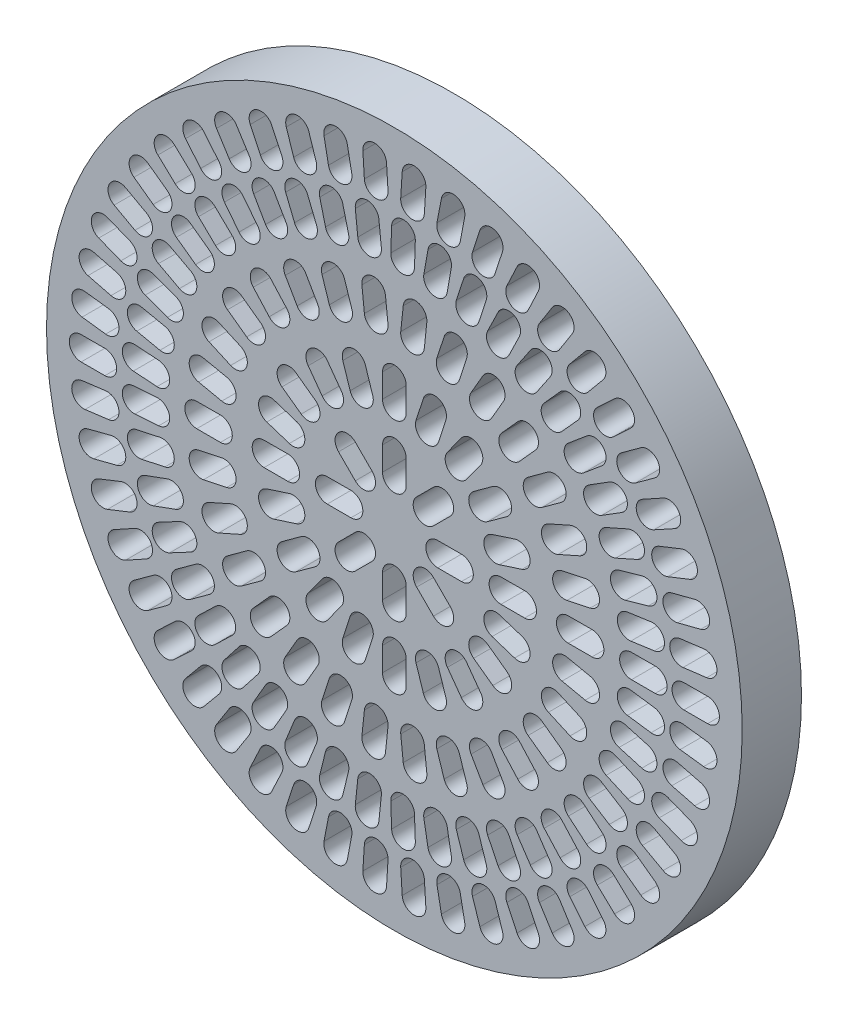
from build123d import *

# Parameters (mm, degrees)
SKETCH1_R           = 29.34
BOSS_EXTRUDE1_DEPTH = 5


with BuildPart() as part:
    # Sketch1 → Boss-Extrude1 (new body)
    with BuildSketch(Plane.XY):
        Circle(SKETCH1_R)
        with BuildLine():
            Line((3.66, 1), (5.66, 1))
            ThreePointArc((5.66, 1), (6.66, 0), (5.66, -1))
            Line((5.66, -1), (3.66, -1))
            ThreePointArc((3.66, -1), (2.66, 0), (3.66, 1))
        make_face(mode=Mode.SUBTRACT)
        with BuildLine():
            Line((10.99, -1), (8.99, -1))
            ThreePointArc((8.99, -1), (7.99, 0), (8.99, 1))
            Line((8.99, 1), (10.99, 1))
            ThreePointArc((10.99, 1), (11.99, 0), (10.99, -1))
        make_face(mode=Mode.SUBTRACT)
        with BuildLine():
            Line((14.67, 1), (16.67, 1))
            ThreePointArc((16.67, 1), (17.67, 0), (16.67, -1))
            Line((16.67, -1), (14.67, -1))
            ThreePointArc((14.67, -1), (13.67, 0), (14.67, 1))
        make_face(mode=Mode.SUBTRACT)
        with BuildLine():
            Line((20, 1), (22, 1))
            ThreePointArc((22, 1), (23, 0), (22, -1))
            Line((22, -1), (20, -1))
            ThreePointArc((20, -1), (19, 0), (20, 1))
        make_face(mode=Mode.SUBTRACT)
        with BuildLine():
            Line((24.420042908, 1), (26.420042908, 1))
            ThreePointArc((26.420042908, 1), (27.420042908, 0), (26.420042908, -1))
            Line((26.420042908, -1), (24.420042908, -1))
            ThreePointArc((24.420042908, -1), (23.420042908, 0), (24.420042908, 1))
        make_face(mode=Mode.SUBTRACT)
        with BuildLine():
            Line((3.2951176, -1.880904038), (4.709331163, -3.2951176))
            ThreePointArc((4.709331163, -3.2951176), (4.709331163, -4.709331163), (3.2951176, -4.709331163))
            Line((3.2951176, -4.709331163), (1.880904038, -3.2951176))
            ThreePointArc((1.880904038, -3.2951176), (1.880904038, -1.880904038), (3.2951176, -1.880904038))
        make_face(mode=Mode.SUBTRACT)
        with BuildLine():
            Line((1, -3.66), (1, -5.66))
            ThreePointArc((1, -5.66), (0, -6.66), (-1, -5.66))
            Line((-1, -5.66), (-1, -3.66))
            ThreePointArc((-1, -3.66), (0, -2.66), (1, -3.66))
        make_face(mode=Mode.SUBTRACT)
        with BuildLine():
            Line((-1.880904038, -3.2951176), (-3.2951176, -4.709331163))
            ThreePointArc((-3.2951176, -4.709331163), (-4.709331163, -4.709331163), (-4.709331163, -3.2951176))
            Line((-4.709331163, -3.2951176), (-3.2951176, -1.880904038))
            ThreePointArc((-3.2951176, -1.880904038), (-1.880904038, -1.880904038), (-1.880904038, -3.2951176))
        make_face(mode=Mode.SUBTRACT)
        with BuildLine():
            Line((-3.66, -1), (-5.66, -1))
            ThreePointArc((-5.66, -1), (-6.66, 0), (-5.66, 1))
            Line((-5.66, 1), (-3.66, 1))
            ThreePointArc((-3.66, 1), (-2.66, 0), (-3.66, -1))
        make_face(mode=Mode.SUBTRACT)
        with BuildLine():
            Line((-3.2951176, 1.880904038), (-4.709331163, 3.2951176))
            ThreePointArc((-4.709331163, 3.2951176), (-4.709331163, 4.709331163), (-3.2951176, 4.709331163))
            Line((-3.2951176, 4.709331163), (-1.880904038, 3.2951176))
            ThreePointArc((-1.880904038, 3.2951176), (-1.880904038, 1.880904038), (-3.2951176, 1.880904038))
        make_face(mode=Mode.SUBTRACT)
        with BuildLine():
            Line((-1, 3.66), (-1, 5.66))
            ThreePointArc((-1, 5.66), (0, 6.66), (1, 5.66))
            Line((1, 5.66), (1, 3.66))
            ThreePointArc((1, 3.66), (0, 2.66), (-1, 3.66))
        make_face(mode=Mode.SUBTRACT)
        with BuildLine():
            Line((1.880904038, 3.2951176), (3.2951176, 4.709331163))
            ThreePointArc((3.2951176, 4.709331163), (4.709331163, 4.709331163), (4.709331163, 3.2951176))
            Line((4.709331163, 3.2951176), (3.2951176, 1.880904038))
            ThreePointArc((3.2951176, 1.880904038), (1.880904038, 1.880904038), (1.880904038, 3.2951176))
        make_face(mode=Mode.SUBTRACT)
        with BuildLine():
            Line((10.14309412, -4.347153284), (8.240981087, -3.729119296))
            ThreePointArc((8.240981087, -3.729119296), (7.598941565, -2.469045785), (8.859015076, -1.827006263))
            Line((8.859015076, -1.827006263), (10.761128108, -2.445040252))
            ThreePointArc((10.761128108, -2.445040252), (11.40316763, -3.705113763), (10.14309412, -4.347153284))
        make_face(mode=Mode.SUBTRACT)
        with BuildLine():
            Line((8.303311516, -7.268776917), (6.685277527, -6.093206412))
            ThreePointArc((6.685277527, -6.093206412), (6.464045785, -4.696404166), (7.860848032, -4.475172424))
            Line((7.860848032, -4.475172424), (9.47888202, -5.650742928))
            ThreePointArc((9.47888202, -5.650742928), (9.700113763, -7.047545175), (8.303311516, -7.268776917))
        make_face(mode=Mode.SUBTRACT)
        with BuildLine():
            Line((5.650742928, -9.47888202), (4.475172424, -7.860848032))
            ThreePointArc((4.475172424, -7.860848032), (4.696404166, -6.464045785), (6.093206412, -6.685277527))
            Line((6.093206412, -6.685277527), (7.268776917, -8.303311516))
            ThreePointArc((7.268776917, -8.303311516), (7.047545175, -9.700113763), (5.650742928, -9.47888202))
        make_face(mode=Mode.SUBTRACT)
        with BuildLine():
            Line((2.445040252, -10.761128108), (1.827006263, -8.859015076))
            ThreePointArc((1.827006263, -8.859015076), (2.469045785, -7.598941565), (3.729119296, -8.240981087))
            Line((3.729119296, -8.240981087), (4.347153284, -10.14309412))
            ThreePointArc((4.347153284, -10.14309412), (3.705113763, -11.40316763), (2.445040252, -10.761128108))
        make_face(mode=Mode.SUBTRACT)
        with BuildLine():
            Line((-1, -10.99), (-1, -8.99))
            ThreePointArc((-1, -8.99), (0, -7.99), (1, -8.99))
            Line((1, -8.99), (1, -10.99))
            ThreePointArc((1, -10.99), (0, -11.99), (-1, -10.99))
        make_face(mode=Mode.SUBTRACT)
        with BuildLine():
            Line((-4.347153284, -10.14309412), (-3.729119296, -8.240981087))
            ThreePointArc((-3.729119296, -8.240981087), (-2.469045785, -7.598941565), (-1.827006263, -8.859015076))
            Line((-1.827006263, -8.859015076), (-2.445040252, -10.761128108))
            ThreePointArc((-2.445040252, -10.761128108), (-3.705113763, -11.40316763), (-4.347153284, -10.14309412))
        make_face(mode=Mode.SUBTRACT)
        with BuildLine():
            Line((-7.268776917, -8.303311516), (-6.093206412, -6.685277527))
            ThreePointArc((-6.093206412, -6.685277527), (-4.696404166, -6.464045785), (-4.475172424, -7.860848032))
            Line((-4.475172424, -7.860848032), (-5.650742928, -9.47888202))
            ThreePointArc((-5.650742928, -9.47888202), (-7.047545175, -9.700113763), (-7.268776917, -8.303311516))
        make_face(mode=Mode.SUBTRACT)
        with BuildLine():
            Line((-9.47888202, -5.650742928), (-7.860848032, -4.475172424))
            ThreePointArc((-7.860848032, -4.475172424), (-6.464045785, -4.696404166), (-6.685277527, -6.093206412))
            Line((-6.685277527, -6.093206412), (-8.303311516, -7.268776917))
            ThreePointArc((-8.303311516, -7.268776917), (-9.700113763, -7.047545175), (-9.47888202, -5.650742928))
        make_face(mode=Mode.SUBTRACT)
        with BuildLine():
            Line((-10.761128108, -2.445040252), (-8.859015076, -1.827006263))
            ThreePointArc((-8.859015076, -1.827006263), (-7.598941565, -2.469045785), (-8.240981087, -3.729119296))
            Line((-8.240981087, -3.729119296), (-10.14309412, -4.347153284))
            ThreePointArc((-10.14309412, -4.347153284), (-11.40316763, -3.705113763), (-10.761128108, -2.445040252))
        make_face(mode=Mode.SUBTRACT)
        with BuildLine():
            Line((-10.99, 1), (-8.99, 1))
            ThreePointArc((-8.99, 1), (-7.99, 0), (-8.99, -1))
            Line((-8.99, -1), (-10.99, -1))
            ThreePointArc((-10.99, -1), (-11.99, 0), (-10.99, 1))
        make_face(mode=Mode.SUBTRACT)
        with BuildLine():
            Line((-10.14309412, 4.347153284), (-8.240981087, 3.729119296))
            ThreePointArc((-8.240981087, 3.729119296), (-7.598941565, 2.469045785), (-8.859015076, 1.827006263))
            Line((-8.859015076, 1.827006263), (-10.761128108, 2.445040252))
            ThreePointArc((-10.761128108, 2.445040252), (-11.40316763, 3.705113763), (-10.14309412, 4.347153284))
        make_face(mode=Mode.SUBTRACT)
        with BuildLine():
            Line((-8.303311516, 7.268776917), (-6.685277527, 6.093206412))
            ThreePointArc((-6.685277527, 6.093206412), (-6.464045785, 4.696404166), (-7.860848032, 4.475172424))
            Line((-7.860848032, 4.475172424), (-9.47888202, 5.650742928))
            ThreePointArc((-9.47888202, 5.650742928), (-9.700113763, 7.047545175), (-8.303311516, 7.268776917))
        make_face(mode=Mode.SUBTRACT)
        with BuildLine():
            Line((-5.650742928, 9.47888202), (-4.475172424, 7.860848032))
            ThreePointArc((-4.475172424, 7.860848032), (-4.696404166, 6.464045785), (-6.093206412, 6.685277527))
            Line((-6.093206412, 6.685277527), (-7.268776917, 8.303311516))
            ThreePointArc((-7.268776917, 8.303311516), (-7.047545175, 9.700113763), (-5.650742928, 9.47888202))
        make_face(mode=Mode.SUBTRACT)
        with BuildLine():
            Line((-2.445040252, 10.761128108), (-1.827006263, 8.859015076))
            ThreePointArc((-1.827006263, 8.859015076), (-2.469045785, 7.598941565), (-3.729119296, 8.240981087))
            Line((-3.729119296, 8.240981087), (-4.347153284, 10.14309412))
            ThreePointArc((-4.347153284, 10.14309412), (-3.705113763, 11.40316763), (-2.445040252, 10.761128108))
        make_face(mode=Mode.SUBTRACT)
        with BuildLine():
            Line((1, 10.99), (1, 8.99))
            ThreePointArc((1, 8.99), (0, 7.99), (-1, 8.99))
            Line((-1, 8.99), (-1, 10.99))
            ThreePointArc((-1, 10.99), (0, 11.99), (1, 10.99))
        make_face(mode=Mode.SUBTRACT)
        with BuildLine():
            Line((4.347153284, 10.14309412), (3.729119296, 8.240981087))
            ThreePointArc((3.729119296, 8.240981087), (2.469045785, 7.598941565), (1.827006263, 8.859015076))
            Line((1.827006263, 8.859015076), (2.445040252, 10.761128108))
            ThreePointArc((2.445040252, 10.761128108), (3.705113763, 11.40316763), (4.347153284, 10.14309412))
        make_face(mode=Mode.SUBTRACT)
        with BuildLine():
            Line((7.268776917, 8.303311516), (6.093206412, 6.685277527))
            ThreePointArc((6.093206412, 6.685277527), (4.696404166, 6.464045785), (4.475172424, 7.860848032))
            Line((4.475172424, 7.860848032), (5.650742928, 9.47888202))
            ThreePointArc((5.650742928, 9.47888202), (7.047545175, 9.700113763), (7.268776917, 8.303311516))
        make_face(mode=Mode.SUBTRACT)
        with BuildLine():
            Line((9.47888202, 5.650742928), (7.860848032, 4.475172424))
            ThreePointArc((7.860848032, 4.475172424), (6.464045785, 4.696404166), (6.685277527, 6.093206412))
            Line((6.685277527, 6.093206412), (8.303311516, 7.268776917))
            ThreePointArc((8.303311516, 7.268776917), (9.700113763, 7.047545175), (9.47888202, 5.650742928))
        make_face(mode=Mode.SUBTRACT)
        with BuildLine():
            Line((10.761128108, 2.445040252), (8.859015076, 1.827006263))
            ThreePointArc((8.859015076, 1.827006263), (7.598941565, 2.469045785), (8.240981087, 3.729119296))
            Line((8.240981087, 3.729119296), (10.14309412, 4.347153284))
            ThreePointArc((10.14309412, 4.347153284), (11.40316763, 3.705113763), (10.761128108, 2.445040252))
        make_face(mode=Mode.SUBTRACT)
        with BuildLine():
            Line((14.557336994, -2.071916904), (16.513632195, -2.487740285))
            ThreePointArc((16.513632195, -2.487740285), (17.283868105, -3.673799577), (16.097808813, -4.444035487))
            Line((16.097808813, -4.444035487), (14.141513612, -4.028212105))
            ThreePointArc((14.141513612, -4.028212105), (13.371277702, -2.842152813), (14.557336994, -2.071916904))
        make_face(mode=Mode.SUBTRACT)
        with BuildLine():
            Line((13.808448507, -5.053281096), (15.635539422, -5.866754382))
            ThreePointArc((15.635539422, -5.866754382), (16.142348237, -7.187036483), (14.822066136, -7.693845298))
            Line((14.822066136, -7.693845298), (12.994975221, -6.880372012))
            ThreePointArc((12.994975221, -6.880372012), (12.488166406, -5.560089911), (13.808448507, -5.053281096))
        make_face(mode=Mode.SUBTRACT)
        with BuildLine():
            Line((12.45606456, -7.813792657), (14.074098549, -8.989363161))
            ThreePointArc((14.074098549, -8.989363161), (14.295330291, -10.386165408), (12.898528044, -10.60739715))
            Line((12.898528044, -10.60739715), (11.280494055, -9.431826646))
            ThreePointArc((11.280494055, -9.431826646), (11.059262313, -8.035024399), (12.45606456, -7.813792657))
        make_face(mode=Mode.SUBTRACT)
        with BuildLine():
            Line((10.559290821, -10.232803983), (11.897552033, -11.719093634))
            ThreePointArc((11.897552033, -11.719093634), (11.823537814, -13.131369066), (10.411262383, -13.057354847))
            Line((10.411262383, -13.057354847), (9.07300117, -11.571065196))
            ThreePointArc((9.07300117, -11.571065196), (9.147015389, -10.158789764), (10.559290821, -10.232803983))
        make_face(mode=Mode.SUBTRACT)
        with BuildLine():
            Line((8.201025404, -12.204592674), (9.201025404, -13.936643481))
            ThreePointArc((9.201025404, -13.936643481), (8.835, -15.302668885), (7.468974596, -14.936643481))
            Line((7.468974596, -14.936643481), (6.468974596, -13.204592674))
            ThreePointArc((6.468974596, -13.204592674), (6.835, -11.83856727), (8.201025404, -12.204592674))
        make_face(mode=Mode.SUBTRACT)
        with BuildLine():
            Line((5.484335824, -13.6429821), (6.102369813, -15.545095132))
            ThreePointArc((6.102369813, -15.545095132), (5.460330291, -16.805168643), (4.20025678, -16.163129121))
            Line((4.20025678, -16.163129121), (3.582222791, -14.261016088))
            ThreePointArc((3.582222791, -14.261016088), (4.224262313, -13.000942578), (5.484335824, -13.6429821))
        make_face(mode=Mode.SUBTRACT)
        with BuildLine():
            Line((2.527954452, -14.485107742), (2.737011378, -16.474151533))
            ThreePointArc((2.737011378, -16.474151533), (1.847017946, -17.573201891), (0.747967587, -16.683208459))
            Line((0.747967587, -16.683208459), (0.538910661, -14.694164668))
            ThreePointArc((0.538910661, -14.694164668), (1.428904093, -13.59511431), (2.527954452, -14.485107742))
        make_face(mode=Mode.SUBTRACT)
        with BuildLine():
            Line((-0.538910661, -14.694164668), (-0.747967587, -16.683208459))
            ThreePointArc((-0.747967587, -16.683208459), (-1.847017946, -17.573201891), (-2.737011378, -16.474151533))
            Line((-2.737011378, -16.474151533), (-2.527954452, -14.485107742))
            ThreePointArc((-2.527954452, -14.485107742), (-1.428904093, -13.59511431), (-0.538910661, -14.694164668))
        make_face(mode=Mode.SUBTRACT)
        with BuildLine():
            Line((-3.582222791, -14.261016088), (-4.20025678, -16.163129121))
            ThreePointArc((-4.20025678, -16.163129121), (-5.460330291, -16.805168643), (-6.102369813, -15.545095132))
            Line((-6.102369813, -15.545095132), (-5.484335824, -13.6429821))
            ThreePointArc((-5.484335824, -13.6429821), (-4.224262313, -13.000942578), (-3.582222791, -14.261016088))
        make_face(mode=Mode.SUBTRACT)
        with BuildLine():
            Line((-6.468974596, -13.204592674), (-7.468974596, -14.936643481))
            ThreePointArc((-7.468974596, -14.936643481), (-8.835, -15.302668885), (-9.201025404, -13.936643481))
            Line((-9.201025404, -13.936643481), (-8.201025404, -12.204592674))
            ThreePointArc((-8.201025404, -12.204592674), (-6.835, -11.83856727), (-6.468974596, -13.204592674))
        make_face(mode=Mode.SUBTRACT)
        with BuildLine():
            Line((-9.07300117, -11.571065196), (-10.411262383, -13.057354847))
            ThreePointArc((-10.411262383, -13.057354847), (-11.823537814, -13.131369066), (-11.897552033, -11.719093634))
            Line((-11.897552033, -11.719093634), (-10.559290821, -10.232803983))
            ThreePointArc((-10.559290821, -10.232803983), (-9.147015389, -10.158789764), (-9.07300117, -11.571065196))
        make_face(mode=Mode.SUBTRACT)
        with BuildLine():
            Line((-11.280494055, -9.431826646), (-12.898528044, -10.60739715))
            ThreePointArc((-12.898528044, -10.60739715), (-14.295330291, -10.386165408), (-14.074098549, -8.989363161))
            Line((-14.074098549, -8.989363161), (-12.45606456, -7.813792657))
            ThreePointArc((-12.45606456, -7.813792657), (-11.059262313, -8.035024399), (-11.280494055, -9.431826646))
        make_face(mode=Mode.SUBTRACT)
        with BuildLine():
            Line((-12.994975221, -6.880372012), (-14.822066136, -7.693845298))
            ThreePointArc((-14.822066136, -7.693845298), (-16.142348237, -7.187036483), (-15.635539422, -5.866754382))
            Line((-15.635539422, -5.866754382), (-13.808448507, -5.053281096))
            ThreePointArc((-13.808448507, -5.053281096), (-12.488166406, -5.560089911), (-12.994975221, -6.880372012))
        make_face(mode=Mode.SUBTRACT)
        with BuildLine():
            Line((-14.141513612, -4.028212105), (-16.097808813, -4.444035487))
            ThreePointArc((-16.097808813, -4.444035487), (-17.283868105, -3.673799577), (-16.513632195, -2.487740285))
            Line((-16.513632195, -2.487740285), (-14.557336994, -2.071916904))
            ThreePointArc((-14.557336994, -2.071916904), (-13.371277702, -2.842152813), (-14.141513612, -4.028212105))
        make_face(mode=Mode.SUBTRACT)
        with BuildLine():
            Line((-14.67, -1), (-16.67, -1))
            ThreePointArc((-16.67, -1), (-17.67, 0), (-16.67, 1))
            Line((-16.67, 1), (-14.67, 1))
            ThreePointArc((-14.67, 1), (-13.67, 0), (-14.67, -1))
        make_face(mode=Mode.SUBTRACT)
        with BuildLine():
            Line((-14.557336994, 2.071916904), (-16.513632195, 2.487740285))
            ThreePointArc((-16.513632195, 2.487740285), (-17.283868105, 3.673799577), (-16.097808813, 4.444035487))
            Line((-16.097808813, 4.444035487), (-14.141513612, 4.028212105))
            ThreePointArc((-14.141513612, 4.028212105), (-13.371277702, 2.842152813), (-14.557336994, 2.071916904))
        make_face(mode=Mode.SUBTRACT)
        with BuildLine():
            Line((-13.808448507, 5.053281096), (-15.635539422, 5.866754382))
            ThreePointArc((-15.635539422, 5.866754382), (-16.142348237, 7.187036483), (-14.822066136, 7.693845298))
            Line((-14.822066136, 7.693845298), (-12.994975221, 6.880372012))
            ThreePointArc((-12.994975221, 6.880372012), (-12.488166406, 5.560089911), (-13.808448507, 5.053281096))
        make_face(mode=Mode.SUBTRACT)
        with BuildLine():
            Line((-12.45606456, 7.813792657), (-14.074098549, 8.989363161))
            ThreePointArc((-14.074098549, 8.989363161), (-14.295330291, 10.386165408), (-12.898528044, 10.60739715))
            Line((-12.898528044, 10.60739715), (-11.280494055, 9.431826646))
            ThreePointArc((-11.280494055, 9.431826646), (-11.059262313, 8.035024399), (-12.45606456, 7.813792657))
        make_face(mode=Mode.SUBTRACT)
        with BuildLine():
            Line((-10.559290821, 10.232803983), (-11.897552033, 11.719093634))
            ThreePointArc((-11.897552033, 11.719093634), (-11.823537814, 13.131369066), (-10.411262383, 13.057354847))
            Line((-10.411262383, 13.057354847), (-9.07300117, 11.571065196))
            ThreePointArc((-9.07300117, 11.571065196), (-9.147015389, 10.158789764), (-10.559290821, 10.232803983))
        make_face(mode=Mode.SUBTRACT)
        with BuildLine():
            Line((-8.201025404, 12.204592674), (-9.201025404, 13.936643481))
            ThreePointArc((-9.201025404, 13.936643481), (-8.835, 15.302668885), (-7.468974596, 14.936643481))
            Line((-7.468974596, 14.936643481), (-6.468974596, 13.204592674))
            ThreePointArc((-6.468974596, 13.204592674), (-6.835, 11.83856727), (-8.201025404, 12.204592674))
        make_face(mode=Mode.SUBTRACT)
        with BuildLine():
            Line((-5.484335824, 13.6429821), (-6.102369813, 15.545095132))
            ThreePointArc((-6.102369813, 15.545095132), (-5.460330291, 16.805168643), (-4.20025678, 16.163129121))
            Line((-4.20025678, 16.163129121), (-3.582222791, 14.261016088))
            ThreePointArc((-3.582222791, 14.261016088), (-4.224262313, 13.000942578), (-5.484335824, 13.6429821))
        make_face(mode=Mode.SUBTRACT)
        with BuildLine():
            Line((-2.527954452, 14.485107742), (-2.737011378, 16.474151533))
            ThreePointArc((-2.737011378, 16.474151533), (-1.847017946, 17.573201891), (-0.747967587, 16.683208459))
            Line((-0.747967587, 16.683208459), (-0.538910661, 14.694164668))
            ThreePointArc((-0.538910661, 14.694164668), (-1.428904093, 13.59511431), (-2.527954452, 14.485107742))
        make_face(mode=Mode.SUBTRACT)
        with BuildLine():
            Line((0.538910661, 14.694164668), (0.747967587, 16.683208459))
            ThreePointArc((0.747967587, 16.683208459), (1.847017946, 17.573201891), (2.737011378, 16.474151533))
            Line((2.737011378, 16.474151533), (2.527954452, 14.485107742))
            ThreePointArc((2.527954452, 14.485107742), (1.428904093, 13.59511431), (0.538910661, 14.694164668))
        make_face(mode=Mode.SUBTRACT)
        with BuildLine():
            Line((3.582222791, 14.261016088), (4.20025678, 16.163129121))
            ThreePointArc((4.20025678, 16.163129121), (5.460330291, 16.805168643), (6.102369813, 15.545095132))
            Line((6.102369813, 15.545095132), (5.484335824, 13.6429821))
            ThreePointArc((5.484335824, 13.6429821), (4.224262313, 13.000942578), (3.582222791, 14.261016088))
        make_face(mode=Mode.SUBTRACT)
        with BuildLine():
            Line((6.468974596, 13.204592674), (7.468974596, 14.936643481))
            ThreePointArc((7.468974596, 14.936643481), (8.835, 15.302668885), (9.201025404, 13.936643481))
            Line((9.201025404, 13.936643481), (8.201025404, 12.204592674))
            ThreePointArc((8.201025404, 12.204592674), (6.835, 11.83856727), (6.468974596, 13.204592674))
        make_face(mode=Mode.SUBTRACT)
        with BuildLine():
            Line((9.07300117, 11.571065196), (10.411262383, 13.057354847))
            ThreePointArc((10.411262383, 13.057354847), (11.823537814, 13.131369066), (11.897552033, 11.719093634))
            Line((11.897552033, 11.719093634), (10.559290821, 10.232803983))
            ThreePointArc((10.559290821, 10.232803983), (9.147015389, 10.158789764), (9.07300117, 11.571065196))
        make_face(mode=Mode.SUBTRACT)
        with BuildLine():
            Line((11.280494055, 9.431826646), (12.898528044, 10.60739715))
            ThreePointArc((12.898528044, 10.60739715), (14.295330291, 10.386165408), (14.074098549, 8.989363161))
            Line((14.074098549, 8.989363161), (12.45606456, 7.813792657))
            ThreePointArc((12.45606456, 7.813792657), (11.059262313, 8.035024399), (11.280494055, 9.431826646))
        make_face(mode=Mode.SUBTRACT)
        with BuildLine():
            Line((12.994975221, 6.880372012), (14.822066136, 7.693845298))
            ThreePointArc((14.822066136, 7.693845298), (16.142348237, 7.187036483), (15.635539422, 5.866754382))
            Line((15.635539422, 5.866754382), (13.808448507, 5.053281096))
            ThreePointArc((13.808448507, 5.053281096), (12.488166406, 5.560089911), (12.994975221, 6.880372012))
        make_face(mode=Mode.SUBTRACT)
        with BuildLine():
            Line((14.141513612, 4.028212105), (16.097808813, 4.444035487))
            ThreePointArc((16.097808813, 4.444035487), (17.283868105, 3.673799577), (16.513632195, 2.487740285))
            Line((16.513632195, 2.487740285), (14.557336994, 2.071916904))
            ThreePointArc((14.557336994, 2.071916904), (13.371277702, 2.842152813), (14.141513612, 4.028212105))
        make_face(mode=Mode.SUBTRACT)
        with BuildLine():
            Line((19.944534476, -1.79319395), (21.925070613, -2.071540152))
            ThreePointArc((21.925070613, -2.071540152), (22.776165581, -3.200981322), (21.646724411, -4.05207629))
            Line((21.646724411, -4.05207629), (19.666188274, -3.773730088))
            ThreePointArc((19.666188274, -3.773730088), (18.815093306, -2.644288918), (19.944534476, -1.79319395))
        make_face(mode=Mode.SUBTRACT)
        with BuildLine():
            Line((19.500871275, -4.55148542), (21.423394666, -5.102760132))
            ThreePointArc((21.423394666, -5.102760132), (22.109019007, -6.339659184), (20.872119955, -7.025283524))
            Line((20.872119955, -7.025283524), (18.949596563, -6.474008812))
            ThreePointArc((18.949596563, -6.474008812), (18.263972223, -5.237109761), (19.500871275, -4.55148542))
        make_face(mode=Mode.SUBTRACT)
        with BuildLine():
            Line((18.677645796, -7.221187404), (20.504736711, -8.03466069))
            ThreePointArc((20.504736711, -8.03466069), (21.011545526, -9.354942791), (19.691263425, -9.861751605))
            Line((19.691263425, -9.861751605), (17.86417251, -9.048278319))
            ThreePointArc((17.86417251, -9.048278319), (17.357363695, -7.727996218), (18.677645796, -7.221187404))
        make_face(mode=Mode.SUBTRACT)
        with BuildLine():
            Line((17.490881187, -9.750337189), (19.18697738, -10.810175717))
            ThreePointArc((19.18697738, -10.810175717), (19.505106212, -12.188143077), (18.127138851, -12.506271909))
            Line((18.127138851, -12.506271909), (16.431042659, -11.446433381))
            ThreePointArc((16.431042659, -11.446433381), (16.112913827, -10.06846602), (17.490881187, -9.750337189))
        make_face(mode=Mode.SUBTRACT)
        with BuildLine():
            Line((15.963676472, -12.089707751), (17.495765358, -13.37528297))
            ThreePointArc((17.495765358, -13.37528297), (17.619022192, -14.784115023), (16.210190139, -14.907371856))
            Line((16.210190139, -14.907371856), (14.678101253, -13.621796637))
            ThreePointArc((14.678101253, -13.621796637), (14.554844419, -12.212964584), (15.963676472, -12.089707751))
        make_face(mode=Mode.SUBTRACT)
        with BuildLine():
            Line((14.125756953, -14.193765903), (15.464018165, -15.680055554))
            ThreePointArc((15.464018165, -15.680055554), (15.390003946, -17.092330986), (13.977728514, -17.018316767))
            Line((13.977728514, -17.018316767), (12.639467302, -15.532027116))
            ThreePointArc((12.639467302, -15.532027116), (12.713481521, -14.119751684), (14.125756953, -14.193765903))
        make_face(mode=Mode.SUBTRACT)
        with BuildLine():
            Line((12.012895642, -16.021558548), (13.131281449, -17.679633693))
            ThreePointArc((13.131281449, -17.679633693), (12.86143678, -19.067864169), (11.473206304, -18.7980195))
            Line((11.473206304, -18.7980195), (10.354820497, -17.139944355))
            ThreePointArc((10.354820497, -17.139944355), (10.624665166, -15.751713879), (12.012895642, -16.021558548))
        make_face(mode=Mode.SUBTRACT)
        with BuildLine():
            Line((9.666216982, -17.537509779), (10.542959276, -19.335097872))
            ThreePointArc((10.542959276, -19.335097872), (10.082536376, -20.672263065), (8.745371183, -20.211840165))
            Line((8.745371183, -20.211840165), (7.868628889, -18.414252073))
            ThreePointArc((7.868628889, -18.414252073), (8.329051789, -17.07708688), (9.666216982, -17.537509779))
        make_face(mode=Mode.SUBTRACT)
        with BuildLine():
            Line((7.131396404, -18.712113332), (7.749430393, -20.614226364))
            ThreePointArc((7.749430393, -20.614226364), (7.107390871, -21.874299875), (5.84731736, -21.232260353))
            Line((5.84731736, -21.232260353), (5.229283371, -19.33014732))
            ThreePointArc((5.229283371, -19.33014732), (5.871322893, -18.07007381), (7.131396404, -18.712113332))
        make_face(mode=Mode.SUBTRACT)
        with BuildLine():
            Line((4.457771306, -19.522506883), (4.805067662, -21.492122389))
            ThreePointArc((4.805067662, -21.492122389), (3.993908086, -22.650578319), (2.835452156, -21.839418744))
            Line((2.835452156, -21.839418744), (2.4881558, -19.869803238))
            ThreePointArc((2.4881558, -19.869803238), (3.299315376, -18.711347307), (4.457771306, -19.522506883))
        make_face(mode=Mode.SUBTRACT)
        with BuildLine():
            Line((1.697380761, -19.952917044), (1.767179754, -21.951698698))
            ThreePointArc((1.767179754, -21.951698698), (0.802688424, -22.985989021), (-0.2316019, -22.021497691))
            Line((-0.2316019, -22.021497691), (-0.301400893, -20.022716037))
            ThreePointArc((-0.301400893, -20.022716037), (0.663090437, -18.988425713), (1.697380761, -19.952917044))
        make_face(mode=Mode.SUBTRACT)
        with BuildLine():
            Line((-1.09604737, -19.994966371), (-1.305104297, -21.984010161))
            ThreePointArc((-1.305104297, -21.984010161), (-2.404154655, -22.874003593), (-3.294148087, -21.774953235))
            Line((-3.294148087, -21.774953235), (-3.085091161, -19.785909444))
            ThreePointArc((-3.085091161, -19.785909444), (-1.986040802, -18.895916012), (-1.09604737, -19.994966371))
        make_face(mode=Mode.SUBTRACT)
        with BuildLine():
            Line((-3.868142186, -19.647836421), (-4.351985977, -21.588427874))
            ThreePointArc((-4.351985977, -21.588427874), (-5.564203599, -22.316801704), (-6.292577429, -21.104584082))
            Line((-6.292577429, -21.104584082), (-5.808733638, -19.16399263))
            ThreePointArc((-5.808733638, -19.16399263), (-4.596516016, -18.435618799), (-3.868142186, -19.647836421))
        make_face(mode=Mode.SUBTRACT)
        with BuildLine():
            Line((-6.564948014, -18.918283685), (-7.314161201, -20.772651394))
            ThreePointArc((-7.314161201, -20.772651394), (-8.615951649, -21.325228655), (-9.16852891, -20.023438207))
            Line((-9.16852891, -20.023438207), (-8.419315723, -18.169070498))
            ThreePointArc((-8.419315723, -18.169070498), (-7.117525275, -17.616493237), (-6.564948014, -18.918283685))
        make_face(mode=Mode.SUBTRACT)
        with BuildLine():
            Line((-9.133974596, -17.820508076), (-10.133974596, -19.552558883))
            ThreePointArc((-10.133974596, -19.552558883), (-11.5, -19.918584287), (-11.866025404, -18.552558883))
            Line((-11.866025404, -18.552558883), (-10.866025404, -16.820508076))
            ThreePointArc((-10.866025404, -16.820508076), (-9.5, -16.454482672), (-9.133974596, -17.820508076))
        make_face(mode=Mode.SUBTRACT)
        with BuildLine():
            Line((-11.525218753, -16.375876547), (-12.756541704, -17.951898055))
            ThreePointArc((-12.756541704, -17.951898055), (-14.160213932, -18.124247333), (-14.332563211, -16.720575104))
            Line((-14.332563211, -16.720575104), (-13.10124026, -15.144553597))
            ThreePointArc((-13.10124026, -15.144553597), (-11.697568031, -14.972204319), (-11.525218753, -16.375876547))
        make_face(mode=Mode.SUBTRACT)
        with BuildLine():
            Line((-13.692137636, -14.61250721), (-15.130817237, -16.00182395))
            ThreePointArc((-15.130817237, -16.00182395), (-16.544815408, -15.977142521), (-16.520133978, -14.56314435))
            Line((-16.520133978, -14.56314435), (-15.081454377, -13.173827609))
            ThreePointArc((-15.081454377, -13.173827609), (-13.667456206, -13.198509039), (-13.692137636, -14.61250721))
        make_face(mode=Mode.SUBTRACT)
        with BuildLine():
            Line((-15.592554635, -12.56472204), (-17.210588624, -13.740292545))
            ThreePointArc((-17.210588624, -13.740292545), (-18.607390871, -13.519060803), (-18.386159129, -12.122258556))
            Line((-18.386159129, -12.122258556), (-16.76812514, -10.946688051))
            ThreePointArc((-16.76812514, -10.946688051), (-15.371322893, -11.167919794), (-15.592554635, -12.56472204))
        make_face(mode=Mode.SUBTRACT)
        with BuildLine():
            Line((-17.189480294, -10.272378849), (-18.95537548, -11.211321974))
            ThreePointArc((-18.95537548, -11.211321974), (-20.307794636, -10.797845944), (-19.894318606, -9.445426788))
            Line((-19.894318606, -9.445426788), (-18.12842342, -8.506483663))
            ThreePointArc((-18.12842342, -8.506483663), (-16.776004264, -8.919959693), (-17.189480294, -10.272378849))
        make_face(mode=Mode.SUBTRACT)
        with BuildLine():
            Line((-18.451832272, -7.780095487), (-20.331217514, -8.464135774))
            ThreePointArc((-20.331217514, -8.464135774), (-21.612930278, -7.866463296), (-21.015257801, -6.584750532))
            Line((-21.015257801, -6.584750532), (-19.135872559, -5.900710246))
            ThreePointArc((-19.135872559, -5.900710246), (-17.854159795, -6.498382723), (-18.451832272, -7.780095487))
        make_face(mode=Mode.SUBTRACT)
        with BuildLine():
            Line((-19.355040324, -5.136381417), (-21.311335525, -5.552204799))
            ThreePointArc((-21.311335525, -5.552204799), (-22.497394817, -4.781968889), (-21.727158907, -3.595909597))
            Line((-21.727158907, -3.595909597), (-19.770863705, -3.180086216))
            ThreePointArc((-19.770863705, -3.180086216), (-18.584804414, -3.950322126), (-19.355040324, -5.136381417))
        make_face(mode=Mode.SUBTRACT)
        with BuildLine():
            Line((-19.881524531, -2.392693525), (-21.876652632, -2.532206473))
            ThreePointArc((-21.876652632, -2.532206473), (-22.943973156, -1.604398896), (-22.016165579, -0.537078372))
            Line((-22.016165579, -0.537078372), (-20.021037479, -0.397565425))
            ThreePointArc((-20.021037479, -0.397565425), (-18.953716955, -1.325373001), (-19.881524531, -2.392693525))
        make_face(mode=Mode.SUBTRACT)
        with BuildLine():
            Line((-20.021037479, 0.397565425), (-22.016165579, 0.537078372))
            ThreePointArc((-22.016165579, 0.537078372), (-22.943973156, 1.604398896), (-21.876652632, 2.532206473))
            Line((-21.876652632, 2.532206473), (-19.881524531, 2.392693525))
            ThreePointArc((-19.881524531, 2.392693525), (-18.953716955, 1.325373001), (-20.021037479, 0.397565425))
        make_face(mode=Mode.SUBTRACT)
        with BuildLine():
            Line((-19.770863705, 3.180086216), (-21.727158907, 3.595909597))
            ThreePointArc((-21.727158907, 3.595909597), (-22.497394817, 4.781968889), (-21.311335525, 5.552204799))
            Line((-21.311335525, 5.552204799), (-19.355040324, 5.136381417))
            ThreePointArc((-19.355040324, 5.136381417), (-18.584804414, 3.950322126), (-19.770863705, 3.180086216))
        make_face(mode=Mode.SUBTRACT)
        with BuildLine():
            Line((-19.135872559, 5.900710246), (-21.015257801, 6.584750532))
            ThreePointArc((-21.015257801, 6.584750532), (-21.612930278, 7.866463296), (-20.331217514, 8.464135774))
            Line((-20.331217514, 8.464135774), (-18.451832272, 7.780095487))
            ThreePointArc((-18.451832272, 7.780095487), (-17.854159795, 6.498382723), (-19.135872559, 5.900710246))
        make_face(mode=Mode.SUBTRACT)
        with BuildLine():
            Line((-18.12842342, 8.506483663), (-19.894318606, 9.445426788))
            ThreePointArc((-19.894318606, 9.445426788), (-20.307794636, 10.797845944), (-18.95537548, 11.211321974))
            Line((-18.95537548, 11.211321974), (-17.189480294, 10.272378849))
            ThreePointArc((-17.189480294, 10.272378849), (-16.776004264, 8.919959693), (-18.12842342, 8.506483663))
        make_face(mode=Mode.SUBTRACT)
        with BuildLine():
            Line((-16.76812514, 10.946688051), (-18.386159129, 12.122258556))
            ThreePointArc((-18.386159129, 12.122258556), (-18.607390871, 13.519060803), (-17.210588624, 13.740292545))
            Line((-17.210588624, 13.740292545), (-15.592554635, 12.56472204))
            ThreePointArc((-15.592554635, 12.56472204), (-15.371322893, 11.167919794), (-16.76812514, 10.946688051))
        make_face(mode=Mode.SUBTRACT)
        with BuildLine():
            Line((-15.081454377, 13.173827609), (-16.520133978, 14.56314435))
            ThreePointArc((-16.520133978, 14.56314435), (-16.544815408, 15.977142521), (-15.130817237, 16.00182395))
            Line((-15.130817237, 16.00182395), (-13.692137636, 14.61250721))
            ThreePointArc((-13.692137636, 14.61250721), (-13.667456206, 13.198509039), (-15.081454377, 13.173827609))
        make_face(mode=Mode.SUBTRACT)
        with BuildLine():
            Line((-13.10124026, 15.144553597), (-14.332563211, 16.720575104))
            ThreePointArc((-14.332563211, 16.720575104), (-14.160213932, 18.124247333), (-12.756541704, 17.951898055))
            Line((-12.756541704, 17.951898055), (-11.525218753, 16.375876547))
            ThreePointArc((-11.525218753, 16.375876547), (-11.697568031, 14.972204319), (-13.10124026, 15.144553597))
        make_face(mode=Mode.SUBTRACT)
        with BuildLine():
            Line((-10.866025404, 16.820508076), (-11.866025404, 18.552558883))
            ThreePointArc((-11.866025404, 18.552558883), (-11.5, 19.918584287), (-10.133974596, 19.552558883))
            Line((-10.133974596, 19.552558883), (-9.133974596, 17.820508076))
            ThreePointArc((-9.133974596, 17.820508076), (-9.5, 16.454482672), (-10.866025404, 16.820508076))
        make_face(mode=Mode.SUBTRACT)
        with BuildLine():
            Line((-8.419315723, 18.169070498), (-9.16852891, 20.023438207))
            ThreePointArc((-9.16852891, 20.023438207), (-8.615951649, 21.325228655), (-7.314161201, 20.772651394))
            Line((-7.314161201, 20.772651394), (-6.564948014, 18.918283685))
            ThreePointArc((-6.564948014, 18.918283685), (-7.117525275, 17.616493237), (-8.419315723, 18.169070498))
        make_face(mode=Mode.SUBTRACT)
        with BuildLine():
            Line((-5.808733638, 19.16399263), (-6.292577429, 21.104584082))
            ThreePointArc((-6.292577429, 21.104584082), (-5.564203599, 22.316801704), (-4.351985977, 21.588427874))
            Line((-4.351985977, 21.588427874), (-3.868142186, 19.647836421))
            ThreePointArc((-3.868142186, 19.647836421), (-4.596516016, 18.435618799), (-5.808733638, 19.16399263))
        make_face(mode=Mode.SUBTRACT)
        with BuildLine():
            Line((-3.085091161, 19.785909444), (-3.294148087, 21.774953235))
            ThreePointArc((-3.294148087, 21.774953235), (-2.404154655, 22.874003593), (-1.305104297, 21.984010161))
            Line((-1.305104297, 21.984010161), (-1.09604737, 19.994966371))
            ThreePointArc((-1.09604737, 19.994966371), (-1.986040802, 18.895916012), (-3.085091161, 19.785909444))
        make_face(mode=Mode.SUBTRACT)
        with BuildLine():
            Line((-0.301400893, 20.022716037), (-0.2316019, 22.021497691))
            ThreePointArc((-0.2316019, 22.021497691), (0.802688424, 22.985989021), (1.767179754, 21.951698698))
            Line((1.767179754, 21.951698698), (1.697380761, 19.952917044))
            ThreePointArc((1.697380761, 19.952917044), (0.663090437, 18.988425713), (-0.301400893, 20.022716037))
        make_face(mode=Mode.SUBTRACT)
        with BuildLine():
            Line((2.4881558, 19.869803238), (2.835452156, 21.839418744))
            ThreePointArc((2.835452156, 21.839418744), (3.993908086, 22.650578319), (4.805067662, 21.492122389))
            Line((4.805067662, 21.492122389), (4.457771306, 19.522506883))
            ThreePointArc((4.457771306, 19.522506883), (3.299315376, 18.711347307), (2.4881558, 19.869803238))
        make_face(mode=Mode.SUBTRACT)
        with BuildLine():
            Line((5.229283371, 19.33014732), (5.84731736, 21.232260353))
            ThreePointArc((5.84731736, 21.232260353), (7.107390871, 21.874299875), (7.749430393, 20.614226364))
            Line((7.749430393, 20.614226364), (7.131396404, 18.712113332))
            ThreePointArc((7.131396404, 18.712113332), (5.871322893, 18.07007381), (5.229283371, 19.33014732))
        make_face(mode=Mode.SUBTRACT)
        with BuildLine():
            Line((7.868628889, 18.414252073), (8.745371183, 20.211840165))
            ThreePointArc((8.745371183, 20.211840165), (10.082536376, 20.672263065), (10.542959276, 19.335097872))
            Line((10.542959276, 19.335097872), (9.666216982, 17.537509779))
            ThreePointArc((9.666216982, 17.537509779), (8.329051789, 17.07708688), (7.868628889, 18.414252073))
        make_face(mode=Mode.SUBTRACT)
        with BuildLine():
            Line((10.354820497, 17.139944355), (11.473206304, 18.7980195))
            ThreePointArc((11.473206304, 18.7980195), (12.86143678, 19.067864169), (13.131281449, 17.679633693))
            Line((13.131281449, 17.679633693), (12.012895642, 16.021558548))
            ThreePointArc((12.012895642, 16.021558548), (10.624665166, 15.751713879), (10.354820497, 17.139944355))
        make_face(mode=Mode.SUBTRACT)
        with BuildLine():
            Line((12.639467302, 15.532027116), (13.977728514, 17.018316767))
            ThreePointArc((13.977728514, 17.018316767), (15.390003946, 17.092330986), (15.464018165, 15.680055554))
            Line((15.464018165, 15.680055554), (14.125756953, 14.193765903))
            ThreePointArc((14.125756953, 14.193765903), (12.713481521, 14.119751684), (12.639467302, 15.532027116))
        make_face(mode=Mode.SUBTRACT)
        with BuildLine():
            Line((14.678101253, 13.621796637), (16.210190139, 14.907371856))
            ThreePointArc((16.210190139, 14.907371856), (17.619022192, 14.784115023), (17.495765358, 13.37528297))
            Line((17.495765358, 13.37528297), (15.963676472, 12.089707751))
            ThreePointArc((15.963676472, 12.089707751), (14.554844419, 12.212964584), (14.678101253, 13.621796637))
        make_face(mode=Mode.SUBTRACT)
        with BuildLine():
            Line((16.431042659, 11.446433381), (18.127138851, 12.506271909))
            ThreePointArc((18.127138851, 12.506271909), (19.505106212, 12.188143077), (19.18697738, 10.810175717))
            Line((19.18697738, 10.810175717), (17.490881187, 9.750337189))
            ThreePointArc((17.490881187, 9.750337189), (16.112913827, 10.06846602), (16.431042659, 11.446433381))
        make_face(mode=Mode.SUBTRACT)
        with BuildLine():
            Line((17.86417251, 9.048278319), (19.691263425, 9.861751605))
            ThreePointArc((19.691263425, 9.861751605), (21.011545526, 9.354942791), (20.504736711, 8.03466069))
            Line((20.504736711, 8.03466069), (18.677645796, 7.221187404))
            ThreePointArc((18.677645796, 7.221187404), (17.357363695, 7.727996218), (17.86417251, 9.048278319))
        make_face(mode=Mode.SUBTRACT)
        with BuildLine():
            Line((18.949596563, 6.474008812), (20.872119955, 7.025283524))
            ThreePointArc((20.872119955, 7.025283524), (22.109019007, 6.339659184), (21.423394666, 5.102760132))
            Line((21.423394666, 5.102760132), (19.500871275, 4.55148542))
            ThreePointArc((19.500871275, 4.55148542), (18.263972223, 5.237109761), (18.949596563, 6.474008812))
        make_face(mode=Mode.SUBTRACT)
        with BuildLine():
            Line((19.666188274, 3.773730088), (21.646724411, 4.05207629))
            ThreePointArc((21.646724411, 4.05207629), (22.776165581, 3.200981322), (21.925070613, 2.071540152))
            Line((21.925070613, 2.071540152), (19.944534476, 1.79319395))
            ThreePointArc((19.944534476, 1.79319395), (18.815093306, 2.644288918), (19.666188274, 3.773730088))
        make_face(mode=Mode.SUBTRACT)
        with BuildLine():
            Line((24.352816809, -2.06852824), (26.337046212, -2.319194707))
            ThreePointArc((26.337046212, -2.319194707), (27.20382768, -3.436642642), (26.086379745, -4.30342411))
            Line((26.086379745, -4.30342411), (24.102150342, -4.052757643))
            ThreePointArc((24.102150342, -4.052757643), (23.235368875, -2.935309708), (24.352816809, -2.06852824))
        make_face(mode=Mode.SUBTRACT)
        with BuildLine():
            Line((23.901532242, -5.104434554), (25.838698564, -5.601814329))
            ThreePointArc((25.838698564, -5.601814329), (26.558591838, -6.819087377), (25.34131879, -7.538980651))
            Line((25.34131879, -7.538980651), (23.404152468, -7.041600876))
            ThreePointArc((23.404152468, -7.041600876), (22.684259194, -5.824327828), (23.901532242, -5.104434554))
        make_face(mode=Mode.SUBTRACT)
        with BuildLine():
            Line((23.073306233, -8.059840886), (24.932859205, -8.796089992))
            ThreePointArc((24.932859205, -8.796089992), (25.494511138, -10.09399103), (24.196610099, -10.655642963))
            Line((24.196610099, -10.655642963), (22.337057128, -9.919393858))
            ThreePointArc((22.337057128, -9.919393858), (21.775405194, -8.621492819), (23.073306233, -8.059840886))
        make_face(mode=Mode.SUBTRACT)
        with BuildLine():
            Line((21.881200401, -10.888138713), (23.633813761, -11.851646061))
            ThreePointArc((23.633813761, -11.851646061), (24.028366767, -13.209706415), (22.670306413, -13.604259421))
            Line((22.670306413, -13.604259421), (20.917693053, -12.640752073))
            ThreePointArc((20.917693053, -12.640752073), (20.523140047, -11.282691719), (21.881200401, -10.888138713))
        make_face(mode=Mode.SUBTRACT)
        with BuildLine():
            Line((20.344014968, -13.544724087), (21.962048957, -14.720294592))
            ThreePointArc((21.962048957, -14.720294592), (22.183280699, -16.117096839), (20.786478452, -16.338328581))
            Line((20.786478452, -16.338328581), (19.168444464, -15.162758076))
            ThreePointArc((19.168444464, -15.162758076), (18.947212722, -13.765955829), (20.344014968, -13.544724087))
        make_face(mode=Mode.SUBTRACT)
        with BuildLine():
            Line((18.485992266, -15.987701072), (19.943929521, -17.356795284))
            ThreePointArc((19.943929521, -17.356795284), (19.988351043, -18.770311017), (18.574835309, -18.814732539))
            Line((18.574835309, -18.814732539), (17.116898054, -17.445638327))
            ThreePointArc((17.116898054, -17.445638327), (17.072476533, -16.032122593), (18.485992266, -15.987701072))
        make_face(mode=Mode.SUBTRACT)
        with BuildLine():
            Line((16.336434423, -18.17854246), (17.611282403, -19.719568946))
            ThreePointArc((17.611282403, -19.719568946), (17.47819315, -21.127506178), (16.070255917, -20.994416925))
            Line((16.070255917, -20.994416925), (14.795407938, -19.45339044))
            ThreePointArc((14.795407938, -19.45339044), (14.928497191, -18.045453207), (16.336434423, -18.17854246))
        make_face(mode=Mode.SUBTRACT)
        with BuildLine():
            Line((13.92924125, -20.082697374), (15.00089484, -21.771353225))
            ThreePointArc((15.00089484, -21.771353225), (14.69239371, -23.151507946), (13.312238989, -22.843006815))
            Line((13.312238989, -22.843006815), (12.240585399, -21.154350964))
            ThreePointArc((12.240585399, -21.154350964), (12.54908653, -19.774196244), (13.92924125, -20.082697374))
        make_face(mode=Mode.SUBTRACT)
        with BuildLine():
            Line((11.302375622, -21.670136154), (12.153934205, -23.479790259))
            ThreePointArc((12.153934205, -23.479790259), (11.674886444, -24.810396603), (10.3442801, -24.331348842))
            Line((10.3442801, -24.331348842), (9.492721517, -22.521694737))
            ThreePointArc((9.492721517, -22.521694737), (9.971769278, -21.191088393), (11.302375622, -21.670136154))
        make_face(mode=Mode.SUBTRACT)
        with BuildLine():
            Line((8.497264778, -22.915823942), (9.115298767, -24.817936974))
            ThreePointArc((9.115298767, -24.817936974), (8.473259245, -26.078010485), (7.213185734, -25.435970963))
            Line((7.213185734, -25.435970963), (6.595151746, -23.53385793))
            ThreePointArc((6.595151746, -23.53385793), (7.237191268, -22.27378442), (8.497264778, -22.915823942))
        make_face(mode=Mode.SUBTRACT)
        with BuildLine():
            Line((5.558146993, -23.800115496), (5.932909622, -25.764689998))
            ThreePointArc((5.932909622, -25.764689998), (5.138003686, -26.934358563), (3.968335121, -26.139452627))
            Line((3.968335121, -26.139452627), (3.593572492, -24.174878125))
            ThreePointArc((3.593572492, -24.174878125), (4.388478428, -23.00520956), (5.558146993, -23.800115496))
        make_face(mode=Mode.SUBTRACT)
        with BuildLine():
            Line((2.53137391, -24.309065012), (2.656954949, -26.305118469))
            ThreePointArc((2.656954949, -26.305118469), (1.72171874, -27.365935717), (0.660901492, -26.430699508))
            Line((0.660901492, -26.430699508), (0.535320453, -24.434646051))
            ThreePointArc((0.535320453, -24.434646051), (1.470556662, -23.373828803), (2.53137391, -24.309065012))
        make_face(mode=Mode.SUBTRACT)
        with BuildLine():
            Line((-0.535320453, -24.434646051), (-0.660901492, -26.430699508))
            ThreePointArc((-0.660901492, -26.430699508), (-1.72171874, -27.365935717), (-2.656954949, -26.305118469))
            Line((-2.656954949, -26.305118469), (-2.53137391, -24.309065012))
            ThreePointArc((-2.53137391, -24.309065012), (-1.470556662, -23.373828803), (-0.535320453, -24.434646051))
        make_face(mode=Mode.SUBTRACT)
        with BuildLine():
            Line((-3.593572492, -24.174878125), (-3.968335121, -26.139452627))
            ThreePointArc((-3.968335121, -26.139452627), (-5.138003686, -26.934358563), (-5.932909622, -25.764689998))
            Line((-5.932909622, -25.764689998), (-5.558146993, -23.800115496))
            ThreePointArc((-5.558146993, -23.800115496), (-4.388478428, -23.00520956), (-3.593572492, -24.174878125))
        make_face(mode=Mode.SUBTRACT)
        with BuildLine():
            Line((-6.595151746, -23.53385793), (-7.213185734, -25.435970963))
            ThreePointArc((-7.213185734, -25.435970963), (-8.473259245, -26.078010485), (-9.115298767, -24.817936974))
            Line((-9.115298767, -24.817936974), (-8.497264778, -22.915823942))
            ThreePointArc((-8.497264778, -22.915823942), (-7.237191268, -22.27378442), (-6.595151746, -23.53385793))
        make_face(mode=Mode.SUBTRACT)
        with BuildLine():
            Line((-9.492721517, -22.521694737), (-10.3442801, -24.331348842))
            ThreePointArc((-10.3442801, -24.331348842), (-11.674886444, -24.810396603), (-12.153934205, -23.479790259))
            Line((-12.153934205, -23.479790259), (-11.302375622, -21.670136154))
            ThreePointArc((-11.302375622, -21.670136154), (-9.971769278, -21.191088393), (-9.492721517, -22.521694737))
        make_face(mode=Mode.SUBTRACT)
        with BuildLine():
            Line((-12.240585399, -21.154350964), (-13.312238989, -22.843006815))
            ThreePointArc((-13.312238989, -22.843006815), (-14.69239371, -23.151507946), (-15.00089484, -21.771353225))
            Line((-15.00089484, -21.771353225), (-13.92924125, -20.082697374))
            ThreePointArc((-13.92924125, -20.082697374), (-12.54908653, -19.774196244), (-12.240585399, -21.154350964))
        make_face(mode=Mode.SUBTRACT)
        with BuildLine():
            Line((-14.795407938, -19.45339044), (-16.070255917, -20.994416925))
            ThreePointArc((-16.070255917, -20.994416925), (-17.47819315, -21.127506178), (-17.611282403, -19.719568946))
            Line((-17.611282403, -19.719568946), (-16.336434423, -18.17854246))
            ThreePointArc((-16.336434423, -18.17854246), (-14.928497191, -18.045453207), (-14.795407938, -19.45339044))
        make_face(mode=Mode.SUBTRACT)
        with BuildLine():
            Line((-17.116898054, -17.445638327), (-18.574835309, -18.814732539))
            ThreePointArc((-18.574835309, -18.814732539), (-19.988351043, -18.770311017), (-19.943929521, -17.356795284))
            Line((-19.943929521, -17.356795284), (-18.485992266, -15.987701072))
            ThreePointArc((-18.485992266, -15.987701072), (-17.072476533, -16.032122593), (-17.116898054, -17.445638327))
        make_face(mode=Mode.SUBTRACT)
        with BuildLine():
            Line((-19.168444464, -15.162758076), (-20.786478452, -16.338328581))
            ThreePointArc((-20.786478452, -16.338328581), (-22.183280699, -16.117096839), (-21.962048957, -14.720294592))
            Line((-21.962048957, -14.720294592), (-20.344014968, -13.544724087))
            ThreePointArc((-20.344014968, -13.544724087), (-18.947212722, -13.765955829), (-19.168444464, -15.162758076))
        make_face(mode=Mode.SUBTRACT)
        with BuildLine():
            Line((-20.917693053, -12.640752073), (-22.670306413, -13.604259421))
            ThreePointArc((-22.670306413, -13.604259421), (-24.028366767, -13.209706415), (-23.633813761, -11.851646061))
            Line((-23.633813761, -11.851646061), (-21.881200401, -10.888138713))
            ThreePointArc((-21.881200401, -10.888138713), (-20.523140047, -11.282691719), (-20.917693053, -12.640752073))
        make_face(mode=Mode.SUBTRACT)
        with BuildLine():
            Line((-22.337057128, -9.919393858), (-24.196610099, -10.655642963))
            ThreePointArc((-24.196610099, -10.655642963), (-25.494511138, -10.09399103), (-24.932859205, -8.796089992))
            Line((-24.932859205, -8.796089992), (-23.073306233, -8.059840886))
            ThreePointArc((-23.073306233, -8.059840886), (-21.775405194, -8.621492819), (-22.337057128, -9.919393858))
        make_face(mode=Mode.SUBTRACT)
        with BuildLine():
            Line((-23.404152468, -7.041600876), (-25.34131879, -7.538980651))
            ThreePointArc((-25.34131879, -7.538980651), (-26.558591838, -6.819087377), (-25.838698564, -5.601814329))
            Line((-25.838698564, -5.601814329), (-23.901532242, -5.104434554))
            ThreePointArc((-23.901532242, -5.104434554), (-22.684259194, -5.824327828), (-23.404152468, -7.041600876))
        make_face(mode=Mode.SUBTRACT)
        with BuildLine():
            Line((-24.102150342, -4.052757643), (-26.086379745, -4.30342411))
            ThreePointArc((-26.086379745, -4.30342411), (-27.20382768, -3.436642642), (-26.337046212, -2.319194707))
            Line((-26.337046212, -2.319194707), (-24.352816809, -2.06852824))
            ThreePointArc((-24.352816809, -2.06852824), (-23.235368875, -2.935309708), (-24.102150342, -4.052757643))
        make_face(mode=Mode.SUBTRACT)
        with BuildLine():
            Line((-24.420042908, -1), (-26.420042908, -1))
            ThreePointArc((-26.420042908, -1), (-27.420042908, 0), (-26.420042908, 1))
            Line((-26.420042908, 1), (-24.420042908, 1))
            ThreePointArc((-24.420042908, 1), (-23.420042908, 0), (-24.420042908, -1))
        make_face(mode=Mode.SUBTRACT)
        with BuildLine():
            Line((-24.352816809, 2.06852824), (-26.337046212, 2.319194707))
            ThreePointArc((-26.337046212, 2.319194707), (-27.20382768, 3.436642642), (-26.086379745, 4.30342411))
            Line((-26.086379745, 4.30342411), (-24.102150342, 4.052757643))
            ThreePointArc((-24.102150342, 4.052757643), (-23.235368875, 2.935309708), (-24.352816809, 2.06852824))
        make_face(mode=Mode.SUBTRACT)
        with BuildLine():
            Line((-23.901532242, 5.104434554), (-25.838698564, 5.601814329))
            ThreePointArc((-25.838698564, 5.601814329), (-26.558591838, 6.819087377), (-25.34131879, 7.538980651))
            Line((-25.34131879, 7.538980651), (-23.404152468, 7.041600876))
            ThreePointArc((-23.404152468, 7.041600876), (-22.684259194, 5.824327828), (-23.901532242, 5.104434554))
        make_face(mode=Mode.SUBTRACT)
        with BuildLine():
            Line((-23.073306233, 8.059840886), (-24.932859205, 8.796089992))
            ThreePointArc((-24.932859205, 8.796089992), (-25.494511138, 10.09399103), (-24.196610099, 10.655642963))
            Line((-24.196610099, 10.655642963), (-22.337057128, 9.919393858))
            ThreePointArc((-22.337057128, 9.919393858), (-21.775405194, 8.621492819), (-23.073306233, 8.059840886))
        make_face(mode=Mode.SUBTRACT)
        with BuildLine():
            Line((-21.881200401, 10.888138713), (-23.633813761, 11.851646061))
            ThreePointArc((-23.633813761, 11.851646061), (-24.028366767, 13.209706415), (-22.670306413, 13.604259421))
            Line((-22.670306413, 13.604259421), (-20.917693053, 12.640752073))
            ThreePointArc((-20.917693053, 12.640752073), (-20.523140047, 11.282691719), (-21.881200401, 10.888138713))
        make_face(mode=Mode.SUBTRACT)
        with BuildLine():
            Line((-20.344014968, 13.544724087), (-21.962048957, 14.720294592))
            ThreePointArc((-21.962048957, 14.720294592), (-22.183280699, 16.117096839), (-20.786478452, 16.338328581))
            Line((-20.786478452, 16.338328581), (-19.168444464, 15.162758076))
            ThreePointArc((-19.168444464, 15.162758076), (-18.947212722, 13.765955829), (-20.344014968, 13.544724087))
        make_face(mode=Mode.SUBTRACT)
        with BuildLine():
            Line((-18.485992266, 15.987701072), (-19.943929521, 17.356795284))
            ThreePointArc((-19.943929521, 17.356795284), (-19.988351043, 18.770311017), (-18.574835309, 18.814732539))
            Line((-18.574835309, 18.814732539), (-17.116898054, 17.445638327))
            ThreePointArc((-17.116898054, 17.445638327), (-17.072476533, 16.032122593), (-18.485992266, 15.987701072))
        make_face(mode=Mode.SUBTRACT)
        with BuildLine():
            Line((-16.336434423, 18.17854246), (-17.611282403, 19.719568946))
            ThreePointArc((-17.611282403, 19.719568946), (-17.47819315, 21.127506178), (-16.070255917, 20.994416925))
            Line((-16.070255917, 20.994416925), (-14.795407938, 19.45339044))
            ThreePointArc((-14.795407938, 19.45339044), (-14.928497191, 18.045453207), (-16.336434423, 18.17854246))
        make_face(mode=Mode.SUBTRACT)
        with BuildLine():
            Line((-13.92924125, 20.082697374), (-15.00089484, 21.771353225))
            ThreePointArc((-15.00089484, 21.771353225), (-14.69239371, 23.151507946), (-13.312238989, 22.843006815))
            Line((-13.312238989, 22.843006815), (-12.240585399, 21.154350964))
            ThreePointArc((-12.240585399, 21.154350964), (-12.54908653, 19.774196244), (-13.92924125, 20.082697374))
        make_face(mode=Mode.SUBTRACT)
        with BuildLine():
            Line((-11.302375622, 21.670136154), (-12.153934205, 23.479790259))
            ThreePointArc((-12.153934205, 23.479790259), (-11.674886444, 24.810396603), (-10.3442801, 24.331348842))
            Line((-10.3442801, 24.331348842), (-9.492721517, 22.521694737))
            ThreePointArc((-9.492721517, 22.521694737), (-9.971769278, 21.191088393), (-11.302375622, 21.670136154))
        make_face(mode=Mode.SUBTRACT)
        with BuildLine():
            Line((-8.497264778, 22.915823942), (-9.115298767, 24.817936974))
            ThreePointArc((-9.115298767, 24.817936974), (-8.473259245, 26.078010485), (-7.213185734, 25.435970963))
            Line((-7.213185734, 25.435970963), (-6.595151746, 23.53385793))
            ThreePointArc((-6.595151746, 23.53385793), (-7.237191268, 22.27378442), (-8.497264778, 22.915823942))
        make_face(mode=Mode.SUBTRACT)
        with BuildLine():
            Line((-5.558146993, 23.800115496), (-5.932909622, 25.764689998))
            ThreePointArc((-5.932909622, 25.764689998), (-5.138003686, 26.934358563), (-3.968335121, 26.139452627))
            Line((-3.968335121, 26.139452627), (-3.593572492, 24.174878125))
            ThreePointArc((-3.593572492, 24.174878125), (-4.388478428, 23.00520956), (-5.558146993, 23.800115496))
        make_face(mode=Mode.SUBTRACT)
        with BuildLine():
            Line((-2.53137391, 24.309065012), (-2.656954949, 26.305118469))
            ThreePointArc((-2.656954949, 26.305118469), (-1.72171874, 27.365935717), (-0.660901492, 26.430699508))
            Line((-0.660901492, 26.430699508), (-0.535320453, 24.434646051))
            ThreePointArc((-0.535320453, 24.434646051), (-1.470556662, 23.373828803), (-2.53137391, 24.309065012))
        make_face(mode=Mode.SUBTRACT)
        with BuildLine():
            Line((0.535320453, 24.434646051), (0.660901492, 26.430699508))
            ThreePointArc((0.660901492, 26.430699508), (1.72171874, 27.365935717), (2.656954949, 26.305118469))
            Line((2.656954949, 26.305118469), (2.53137391, 24.309065012))
            ThreePointArc((2.53137391, 24.309065012), (1.470556662, 23.373828803), (0.535320453, 24.434646051))
        make_face(mode=Mode.SUBTRACT)
        with BuildLine():
            Line((3.593572492, 24.174878125), (3.968335121, 26.139452627))
            ThreePointArc((3.968335121, 26.139452627), (5.138003686, 26.934358563), (5.932909622, 25.764689998))
            Line((5.932909622, 25.764689998), (5.558146993, 23.800115496))
            ThreePointArc((5.558146993, 23.800115496), (4.388478428, 23.00520956), (3.593572492, 24.174878125))
        make_face(mode=Mode.SUBTRACT)
        with BuildLine():
            Line((6.595151746, 23.53385793), (7.213185734, 25.435970963))
            ThreePointArc((7.213185734, 25.435970963), (8.473259245, 26.078010485), (9.115298767, 24.817936974))
            Line((9.115298767, 24.817936974), (8.497264778, 22.915823942))
            ThreePointArc((8.497264778, 22.915823942), (7.237191268, 22.27378442), (6.595151746, 23.53385793))
        make_face(mode=Mode.SUBTRACT)
        with BuildLine():
            Line((9.492721517, 22.521694737), (10.3442801, 24.331348842))
            ThreePointArc((10.3442801, 24.331348842), (11.674886444, 24.810396603), (12.153934205, 23.479790259))
            Line((12.153934205, 23.479790259), (11.302375622, 21.670136154))
            ThreePointArc((11.302375622, 21.670136154), (9.971769278, 21.191088393), (9.492721517, 22.521694737))
        make_face(mode=Mode.SUBTRACT)
        with BuildLine():
            Line((12.240585399, 21.154350964), (13.312238989, 22.843006815))
            ThreePointArc((13.312238989, 22.843006815), (14.69239371, 23.151507946), (15.00089484, 21.771353225))
            Line((15.00089484, 21.771353225), (13.92924125, 20.082697374))
            ThreePointArc((13.92924125, 20.082697374), (12.54908653, 19.774196244), (12.240585399, 21.154350964))
        make_face(mode=Mode.SUBTRACT)
        with BuildLine():
            Line((14.795407938, 19.45339044), (16.070255917, 20.994416925))
            ThreePointArc((16.070255917, 20.994416925), (17.47819315, 21.127506178), (17.611282403, 19.719568946))
            Line((17.611282403, 19.719568946), (16.336434423, 18.17854246))
            ThreePointArc((16.336434423, 18.17854246), (14.928497191, 18.045453207), (14.795407938, 19.45339044))
        make_face(mode=Mode.SUBTRACT)
        with BuildLine():
            Line((17.116898054, 17.445638327), (18.574835309, 18.814732539))
            ThreePointArc((18.574835309, 18.814732539), (19.988351043, 18.770311017), (19.943929521, 17.356795284))
            Line((19.943929521, 17.356795284), (18.485992266, 15.987701072))
            ThreePointArc((18.485992266, 15.987701072), (17.072476533, 16.032122593), (17.116898054, 17.445638327))
        make_face(mode=Mode.SUBTRACT)
        with BuildLine():
            Line((19.168444464, 15.162758076), (20.786478452, 16.338328581))
            ThreePointArc((20.786478452, 16.338328581), (22.183280699, 16.117096839), (21.962048957, 14.720294592))
            Line((21.962048957, 14.720294592), (20.344014968, 13.544724087))
            ThreePointArc((20.344014968, 13.544724087), (18.947212722, 13.765955829), (19.168444464, 15.162758076))
        make_face(mode=Mode.SUBTRACT)
        with BuildLine():
            Line((20.917693053, 12.640752073), (22.670306413, 13.604259421))
            ThreePointArc((22.670306413, 13.604259421), (24.028366767, 13.209706415), (23.633813761, 11.851646061))
            Line((23.633813761, 11.851646061), (21.881200401, 10.888138713))
            ThreePointArc((21.881200401, 10.888138713), (20.523140047, 11.282691719), (20.917693053, 12.640752073))
        make_face(mode=Mode.SUBTRACT)
        with BuildLine():
            Line((22.337057128, 9.919393858), (24.196610099, 10.655642963))
            ThreePointArc((24.196610099, 10.655642963), (25.494511138, 10.09399103), (24.932859205, 8.796089992))
            Line((24.932859205, 8.796089992), (23.073306233, 8.059840886))
            ThreePointArc((23.073306233, 8.059840886), (21.775405194, 8.621492819), (22.337057128, 9.919393858))
        make_face(mode=Mode.SUBTRACT)
        with BuildLine():
            Line((23.404152468, 7.041600876), (25.34131879, 7.538980651))
            ThreePointArc((25.34131879, 7.538980651), (26.558591838, 6.819087377), (25.838698564, 5.601814329))
            Line((25.838698564, 5.601814329), (23.901532242, 5.104434554))
            ThreePointArc((23.901532242, 5.104434554), (22.684259194, 5.824327828), (23.404152468, 7.041600876))
        make_face(mode=Mode.SUBTRACT)
        with BuildLine():
            Line((24.102150342, 4.052757643), (26.086379745, 4.30342411))
            ThreePointArc((26.086379745, 4.30342411), (27.20382768, 3.436642642), (26.337046212, 2.319194707))
            Line((26.337046212, 2.319194707), (24.352816809, 2.06852824))
            ThreePointArc((24.352816809, 2.06852824), (23.235368875, 2.935309708), (24.102150342, 4.052757643))
        make_face(mode=Mode.SUBTRACT)
    extrude(amount=BOSS_EXTRUDE1_DEPTH)


solid = part.part
